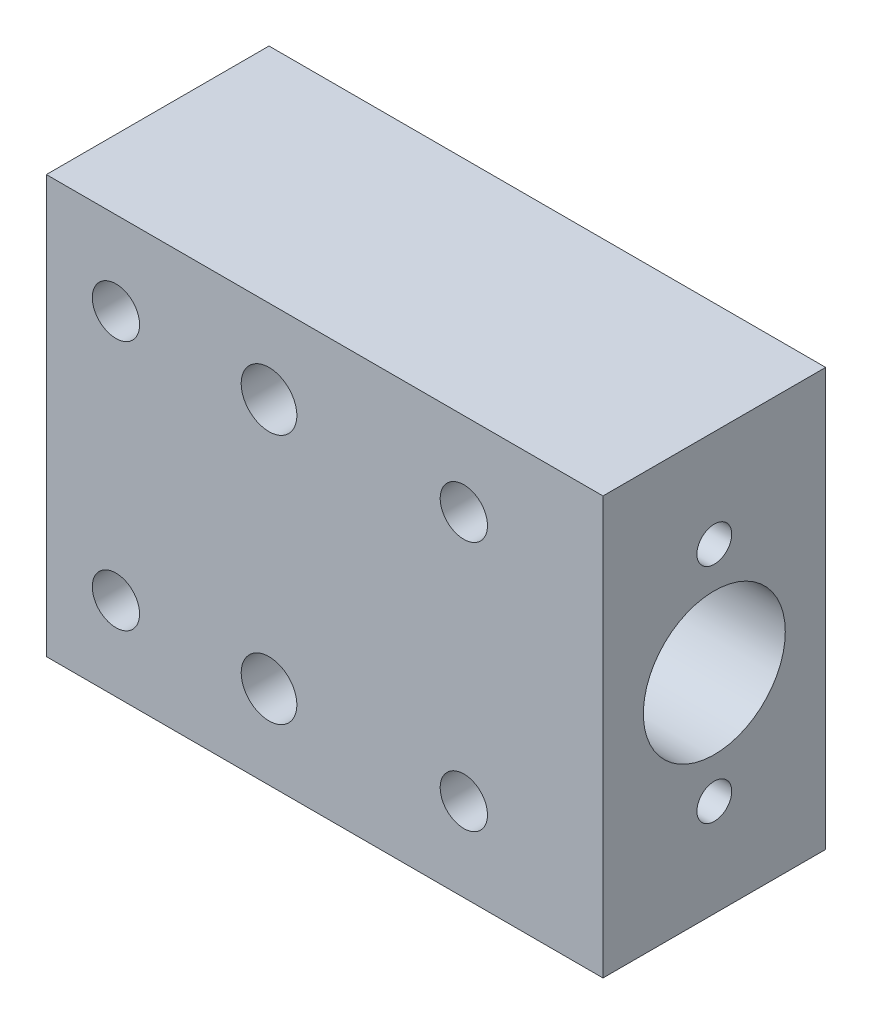
from build123d import *

# Parameters (mm, degrees)
CROQUIS1_W                                           = 40
CROQUIS1_H                                           = 30
SALIENTE_EXTRUIR1_DEPTH                              = 16
CROQUIS2_R                                           = 5.1
CORTAR_EXTRUIR1_DEPTH                                = 41
REFRENTADO_PARA_TORNILLO_CON_CABEZA_HUEC_D           = 3.4
REFRENTADO_PARA_TORNILLO_CON_CABEZA_HUEC_CBORE_D     = 6.5
REFRENTADO_PARA_TORNILLO_CON_CABEZA_HUEC_CBORE_DEPTH = 3.4
DI_METRO_DE_TALADRO_4_0_4_1_D                        = 4
CROQUIS7_R                                           = 1.25
CORTAR_EXTRUIR2_DEPTH                                = 7


with BuildPart() as part:
    # Croquis1 → Saliente-Extruir1 (new body)
    with BuildSketch(Plane.XY):
        with Locations((20, 15)):
            Rectangle(CROQUIS1_W, CROQUIS1_H)
    extrude(amount=SALIENTE_EXTRUIR1_DEPTH)

    # Croquis2 → Cortar-Extruir1 (cut, through all)
    with BuildSketch(Plane(origin=(40, 0, 0), x_dir=(0, 0, -1), z_dir=(1, 0, 0))):
        with Locations((-8, 15)):
            Circle(CROQUIS2_R)
    extrude(amount=-CORTAR_EXTRUIR1_DEPTH, mode=Mode.SUBTRACT)

    # Refrentado para tornillo con cabeza hueca de M31 (through all)
    with Locations(Plane(origin=(0, 0, 0), x_dir=(-1, 0, 0), z_dir=(0, 0, -1))):
        with Locations((-5, 6), (-30, 6), (-30, 24), (-5, 24)):
            CounterBoreHole(REFRENTADO_PARA_TORNILLO_CON_CABEZA_HUEC_D / 2, REFRENTADO_PARA_TORNILLO_CON_CABEZA_HUEC_CBORE_D / 2, REFRENTADO_PARA_TORNILLO_CON_CABEZA_HUEC_CBORE_DEPTH)

    # Diámetro de taladro Ø4.0 (4)1 (through all)
    with Locations(Plane(origin=(0, 0, 0), x_dir=(-1, 0, 0), z_dir=(0, 0, -1))):
        with Locations((-16, 6), (-16, 24)):
            Hole(DI_METRO_DE_TALADRO_4_0_4_1_D / 2)

    # Croquis7 → Cortar-Extruir2 (cut)
    with BuildSketch(Plane(origin=(40, 0, 0), x_dir=(0, 0, -1), z_dir=(1, 0, 0))):
        with Locations((-8, 23)):
            Circle(CROQUIS7_R)
        with Locations((-8, 7)):
            Circle(CROQUIS7_R)
    extrude(amount=-CORTAR_EXTRUIR2_DEPTH, mode=Mode.SUBTRACT)


solid = part.part
